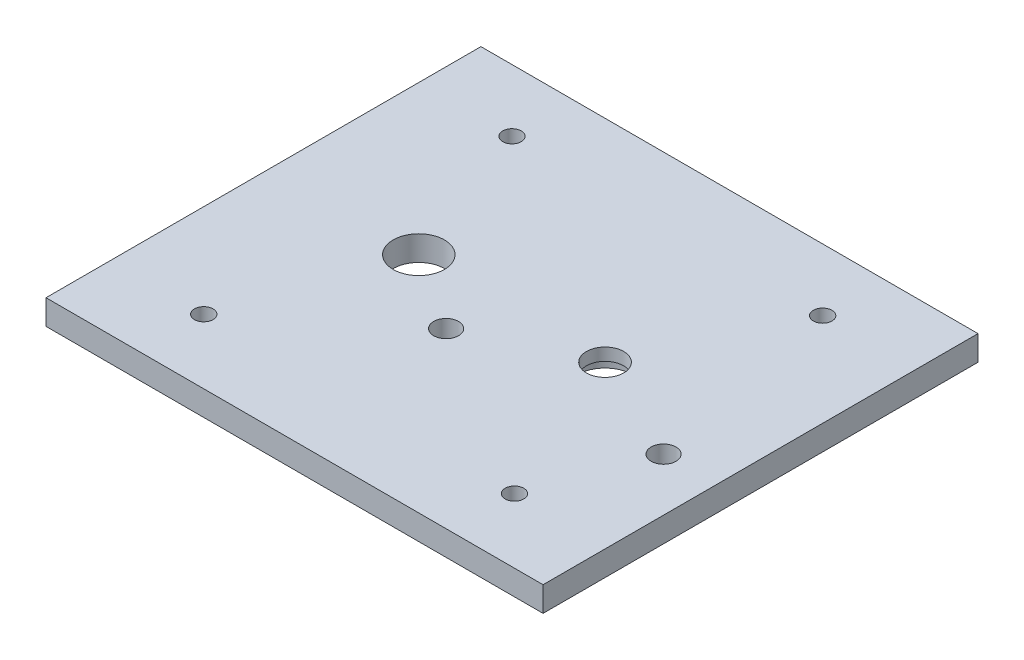
from build123d import *

# Parameters (mm, degrees)
SKETCH1_W           = 80
SKETCH1_H           = 70
SKETCH1_R           = 1.5
SKETCH1_R_2         = 2
SKETCH1_R_3         = 4.125
SKETCH1_R_4         = 3
BOSS_EXTRUDE4_DEPTH = 4
SKETCH1_7_R         = 4.5
CUT_EXTRUDE2_DEPTH  = 2


with BuildPart() as part:
    # Sketch1 → Boss-Extrude4 (new body)
    with BuildSketch(Plane(origin=(0, 0, 0), x_dir=(1, 0, 0), z_dir=(0, 1, 0))):
        Rectangle(SKETCH1_W, SKETCH1_H)
        with Locations((-25, -24.60667729)):
            Circle(SKETCH1_R, mode=Mode.SUBTRACT)
        with Locations((25, -24.60667729)):
            Circle(SKETCH1_R, mode=Mode.SUBTRACT)
        with Locations((31.5, -7.102660735)):
            Circle(SKETCH1_R_2, mode=Mode.SUBTRACT)
        with Locations((-25, 25)):
            Circle(SKETCH1_R, mode=Mode.SUBTRACT)
        with Locations((25, 25)):
            Circle(SKETCH1_R, mode=Mode.SUBTRACT)
        with Locations((-16, 1)):
            Circle(SKETCH1_R_3, mode=Mode.SUBTRACT)
        with Locations((-3.5, -7.102660735)):
            Circle(SKETCH1_R_2, mode=Mode.SUBTRACT)
        with Locations((13.978339488, 0.999882702)):
            Circle(SKETCH1_R_4, mode=Mode.SUBTRACT)
    extrude(amount=BOSS_EXTRUDE4_DEPTH)

    # Sketch1_7 → Cut-Extrude2 (cut)
    with BuildSketch(Plane(origin=(0, 0, 0), x_dir=(1, 0, 0), z_dir=(0, 1, 0))):
        with Locations((13.978339488, 0.999882702)):
            Circle(SKETCH1_7_R)
    extrude(amount=CUT_EXTRUDE2_DEPTH, mode=Mode.SUBTRACT)


solid = part.part
